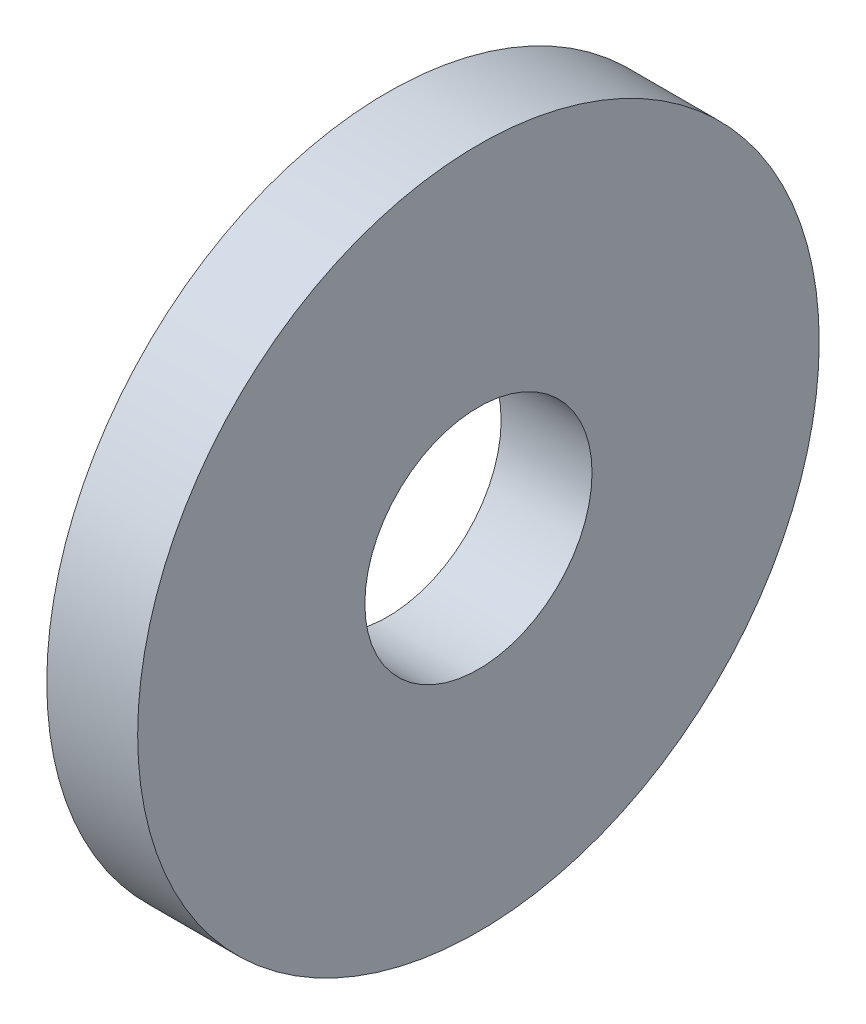
from build123d import *

# Parameters (mm, degrees)
SKETCH_1_R      = 15
SKETCH_1_R_2    = 5
EXTRUDE_1_DEPTH = 4


with BuildPart() as part:
    # 草图1 → 凸台-拉伸1 (new body)
    with BuildSketch(Plane(origin=(0, 0, 0), x_dir=(0, 0, -1), z_dir=(1, 0, 0))):
        Circle(SKETCH_1_R)
        Circle(SKETCH_1_R_2, mode=Mode.SUBTRACT)
    extrude(amount=EXTRUDE_1_DEPTH)


solid = part.part
